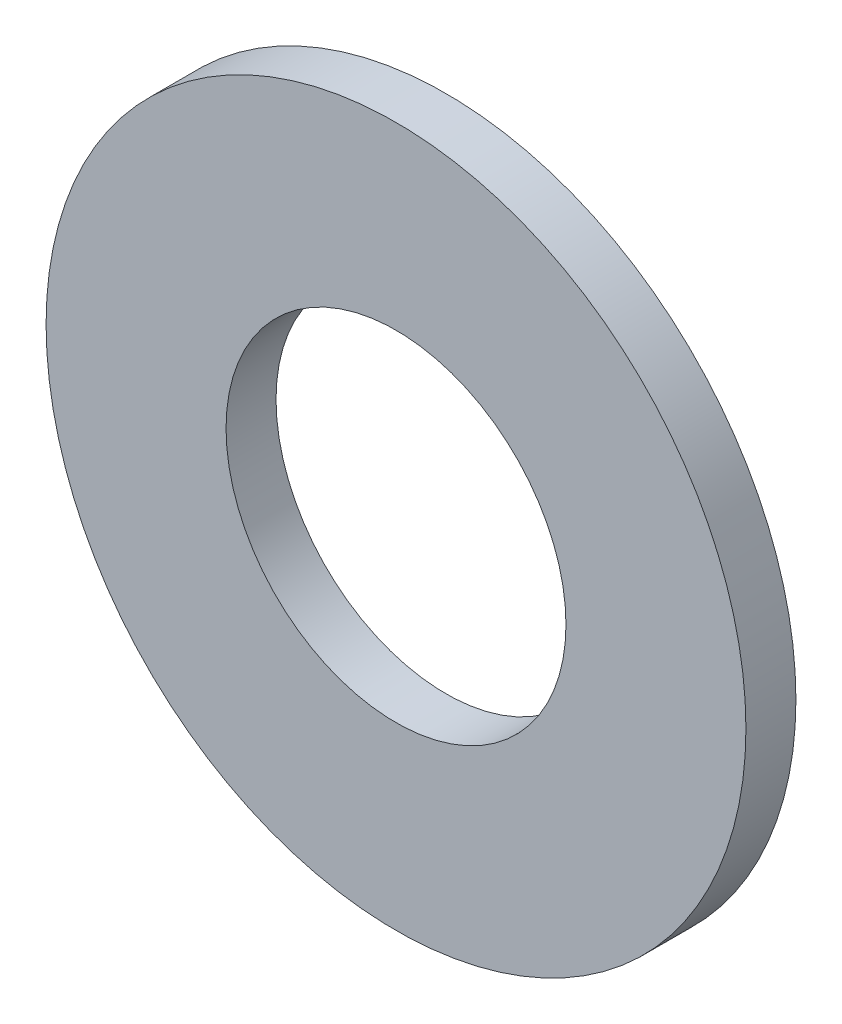
from build123d import *

# Parameters (mm, degrees)
SKETCH_1_R      = 3.5
SKETCH_1_R_2    = 1.7
EXTRUDE_1_DEPTH = 0.25


with BuildPart() as part:
    # 草圖1 → 填料-伸長1 (new body, symmetric)
    with BuildSketch(Plane.XY):
        Circle(SKETCH_1_R)
        Circle(SKETCH_1_R_2, mode=Mode.SUBTRACT)
    extrude(amount=EXTRUDE_1_DEPTH, both=True)


solid = part.part
